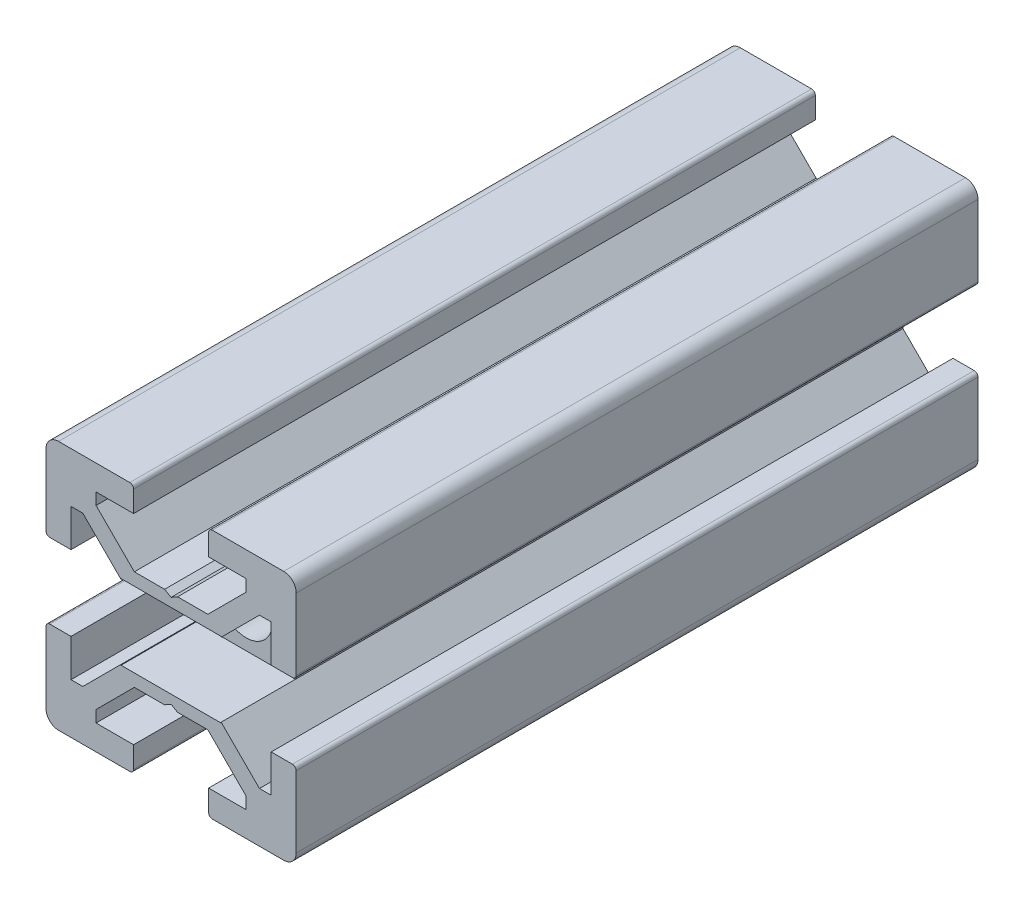
from build123d import *

# Parameters (mm, degrees)
BOSS_EXTRUDE1_DEPTH = 54.5
SKETCH2_W           = 54.5
SKETCH2_H           = 2.1
SKETCH4_R           = 2.5
CUT_EXTRUDE1_DEPTH  = 8
SKETCH5_W           = 6
SKETCH5_H           = 5.999987125
CUT_EXTRUDE2_DEPTH  = 8


with BuildPart() as part:
    # Sketch1 → Boss-Extrude1 (new body)
    with BuildSketch(Plane.XY):
        with BuildLine():
            Line((-10, 9), (-10, 3.29999995))
            ThreePointArc((-10, 3.29999995), (-9.912132049, 3.087867916), (-9.7, 3))
            Line((-9.7, 3), (-8, 3))
            Line((-8, 3), (-8, 6))
            Line((-8, 6), (-7.060677, 6))
            Line((-7.060677, 6), (-4, 2.93932965))
            Line((-4, 2.93932965), (-4, 0.519615242))
            Line((-4, 0.519615242), (-3.699996283, -6.437e-06))
            Line((-3.699996283, -6.437e-06), (-4, -0.519628117))
            Line((-4, -0.519628117), (-4, -2.93933725))
            Line((-4, -2.93933725), (-7.0606695, -6))
            Line((-7.0606695, -6), (-8, -6))
            Line((-8, -6), (-8, -3))
            Line((-8, -3), (-9.7, -3))
            ThreePointArc((-9.7, -3), (-9.912132049, -3.087867916), (-10, -3.29999995))
            Line((-10, -3.29999995), (-10, -9))
            ThreePointArc((-10, -9), (-9.707106781, -9.707106781), (-9, -10))
            Line((-9, -10), (-3.29999995, -10))
            ThreePointArc((-3.29999995, -10), (-3.087867916, -9.912132049), (-3, -9.7))
            Line((-3, -9.7), (-3, -8))
            Line((-3, -8), (-6, -8))
            Line((-6, -8), (-6, -7.0606515))
            Line((-6, -7.0606515), (-2.9393489, -4))
            Line((-2.9393489, -4), (-0.519615242, -4))
            Line((-0.519615242, -4), (6.437e-06, -3.699996283))
            Line((6.437e-06, -3.699996283), (0.519628117, -4))
            Line((0.519628117, -4), (2.9393227, -4))
            Line((2.9393227, -4), (6, -7.060677))
            Line((6, -7.060677), (6, -8))
            Line((6, -8), (3, -8))
            Line((3, -8), (3, -9.7))
            ThreePointArc((3, -9.7), (3.087867916, -9.912132049), (3.29999995, -10))
            Line((3.29999995, -10), (9, -10))
            ThreePointArc((9, -10), (9.707106781, -9.707106781), (10, -9))
            Line((10, -9), (10, -3.29999995))
            ThreePointArc((10, -3.29999995), (9.912132049, -3.087867916), (9.7, -3))
            Line((9.7, -3), (8, -3))
            Line((8, -3), (8, -6))
            Line((8, -6), (7.0606435, -6))
            Line((7.0606435, -6), (4, -2.9393482))
            Line((4, -2.9393482), (4, -0.519615242))
            Line((4, -0.519615242), (3.699996283, 6.437e-06))
            Line((3.699996283, 6.437e-06), (4, 0.519628117))
            Line((4, 0.519628117), (4, 2.9393401))
            Line((4, 2.9393401), (7.060651, 6))
            Line((7.060651, 6), (8, 6))
            Line((8, 6), (8, 3))
            Line((8, 3), (9.7, 3))
            ThreePointArc((9.7, 3), (9.912132049, 3.087867916), (10, 3.29999995))
            Line((10, 3.29999995), (10, 9))
            ThreePointArc((10, 9), (9.707106781, 9.707106781), (9, 10))
            Line((9, 10), (3.29999995, 10))
            ThreePointArc((3.29999995, 10), (3.087867916, 9.912132049), (3, 9.7))
            Line((3, 9.7), (3, 8))
            Line((3, 8), (6, 8))
            Line((6, 8), (6, 7.060669))
            Line((6, 7.060669), (2.9393308, 4))
            Line((2.9393308, 4), (0.519615242, 4))
            Line((0.519615242, 4), (-6.437e-06, 3.699996283))
            Line((-6.437e-06, 3.699996283), (-0.519628117, 4))
            Line((-0.519628117, 4), (-2.93935655, 4))
            Line((-2.93935655, 4), (-6, 7.0606435))
            Line((-6, 7.0606435), (-6, 8))
            Line((-6, 8), (-3, 8))
            Line((-3, 8), (-3, 9.7))
            ThreePointArc((-3, 9.7), (-3.087867966, 9.912132034), (-3.3, 10))
            Line((-3.3, 10), (-9, 10))
            ThreePointArc((-9, 10), (-9.707106781, 9.707106781), (-10, 9))
        make_face()
    extrude(amount=-BOSS_EXTRUDE1_DEPTH)

    # Sketch2 → Cut-Revolve1 (revolve, cut)
    with BuildSketch(Plane(origin=(0, 0, 0), x_dir=(0, 0, -1), z_dir=(1, 0, 0))):
        with Locations((27.25, 1.05)):
            Rectangle(SKETCH2_W, SKETCH2_H)
    revolve(axis=Axis((0, 0, -54.5), (0, 0, 1)), mode=Mode.SUBTRACT)

    # Sketch4 → Cut-Extrude1 (cut)
    with BuildSketch(Plane(origin=(4, 0, 0), x_dir=(0, 0, -1), z_dir=(1, 0, 0))):
        with Locations((10, 6.437e-06)):
            Circle(SKETCH4_R)
    extrude(amount=-CUT_EXTRUDE1_DEPTH, mode=Mode.SUBTRACT)

    # Sketch5 → Cut-Extrude2 (cut)
    with BuildSketch(Plane(origin=(4, 0, 0), x_dir=(0, 0, -1), z_dir=(1, 0, 0))):
        with Locations((3, 6.437e-06)):
            Rectangle(SKETCH5_W, SKETCH5_H)
    extrude(amount=-CUT_EXTRUDE2_DEPTH, mode=Mode.SUBTRACT)


solid = part.part
